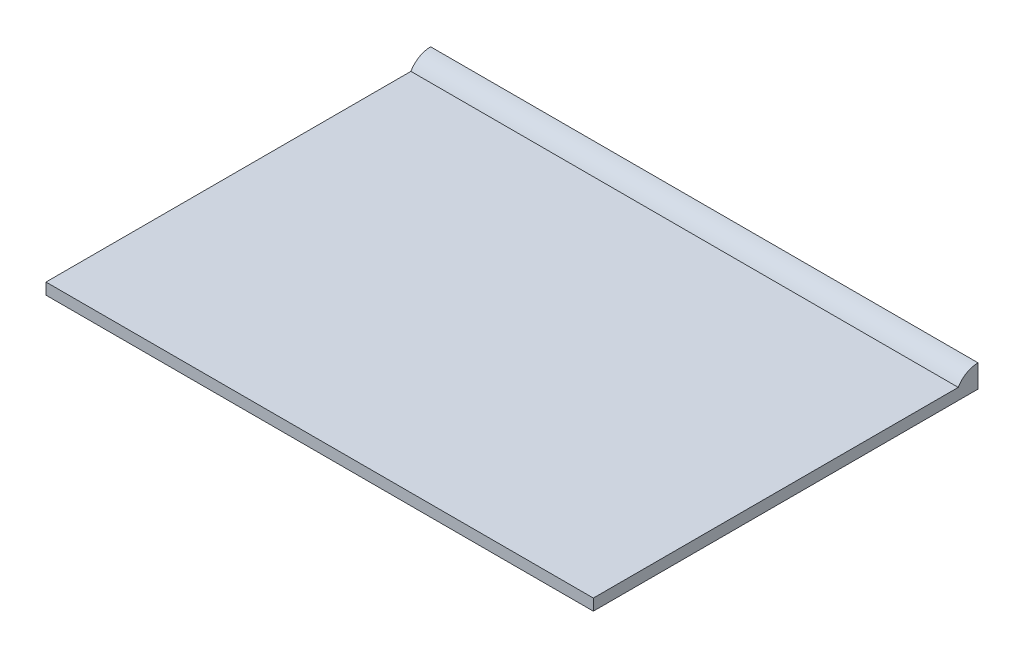
from build123d import *

# Parameters (mm, degrees)
SKETCH1_W           = 19.05
SKETCH1_H           = 12.7
BOSS_EXTRUDE1_DEPTH = 0.79375
SKETCH2_R           = 0.79375
BOSS_EXTRUDE2_DEPTH = 19.05
CUT_EXTRUDE2_DEPTH  = 20.05


with BuildPart() as part:
    # Sketch1 → Boss-Extrude1 (new body)
    with BuildSketch(Plane(origin=(0, 0, 0), x_dir=(1, 0, 0), z_dir=(0, 1, 0))):
        with Locations((9.525, 6.35)):
            Rectangle(SKETCH1_W, SKETCH1_H)
    extrude(amount=BOSS_EXTRUDE1_DEPTH)

    # Sketch2 → Boss-Extrude2 (add)
    with BuildSketch(Plane(origin=(19.05, 0, 0), x_dir=(0, 0, -1), z_dir=(1, 0, 0))):
        with Locations((13.387407664, 0.396875)):
            Circle(SKETCH2_R)
    extrude(amount=-BOSS_EXTRUDE2_DEPTH)

    # Sketch4 → Cut-Extrude2 (cut, through all)
    with BuildSketch(Plane(origin=(19.05, 0, 0), x_dir=(0, 0, -1), z_dir=(1, 0, 0))):
        Polygon((0, 0.396875), (13.387407664, 0.396875), (13.387407664, 1.190625), (14.181157664, 1.190625), (14.181157664, -0.396875), (0, -0.396875), align=None)
    extrude(amount=-CUT_EXTRUDE2_DEPTH, mode=Mode.SUBTRACT)


solid = part.part
